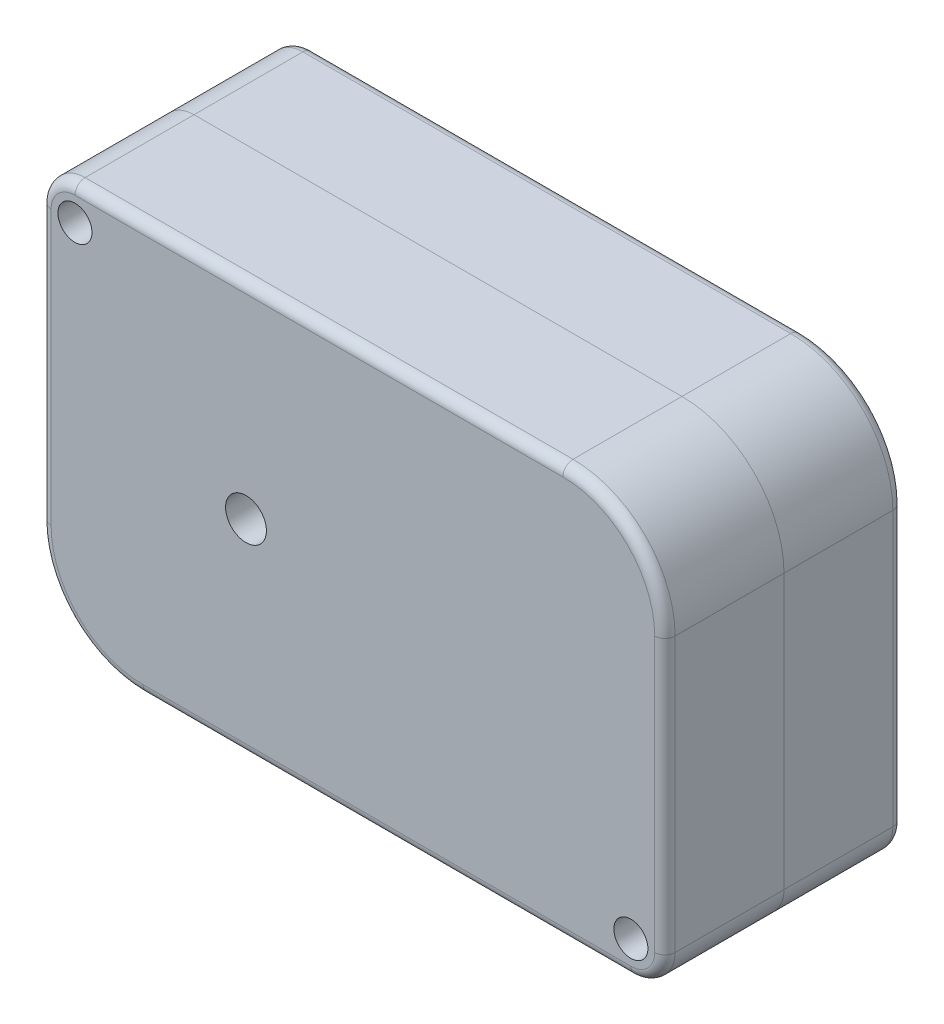
from build123d import *

# Parameters (mm, degrees)
SKETCH1_R           = 5
BOSS_EXTRUDE1_DEPTH = 25
BOSS_EXTRUDE5_DEPTH = 15
BOSS_EXTRUDE2_START = -10
SKETCH1_3_R         = 5
BOSS_EXTRUDE2_DEPTH = 10
FILLET1_R           = 3
SKETCH2_R           = 50
SKETCH2_R_2         = 6
BOSS_EXTRUDE6_DEPTH = 5
SKETCH2_3_R         = 6
CUT_EXTRUDE1_DEPTH  = 154.921216551
SKETCH3_R           = 2.5
CUT_EXTRUDE2_DEPTH  = 20


with BuildPart() as part:
    # Sketch1 → Boss-Extrude1 (new body)
    with BuildSketch(Plane.XY):
        with BuildLine():
            ThreePointArc((-113.122, 60.272), (-120.193067812, 57.343067812), (-123.122, 50.272))
            Line((-123.122, 50.272), (-123.122, -30.272))
            ThreePointArc((-123.122, -30.272), (-114.335203436, -51.485203436), (-93.122, -60.272))
            Line((-93.122, -60.272), (50.272, -60.272))
            ThreePointArc((50.272, -60.272), (57.343067812, -57.343067812), (60.272, -50.272))
            Line((60.272, -50.272), (60.272, 30.272))
            ThreePointArc((60.272, 30.272), (51.485203436, 51.485203436), (30.272, 60.272))
            Line((30.272, 60.272), (-113.122, 60.272))
        make_face()
        with BuildLine():
            ThreePointArc((28.192339385, 53.272), (42.618739916, 42.618739916), (53.272, 28.192339385))
            Line((53.272, 28.192339385), (53.272, -28.192339385))
            ThreePointArc((53.272, -28.192339385), (42.618739916, -42.618739916), (28.192339385, -53.272))
            Line((28.192339385, -53.272), (-91.042339385, -53.272))
            ThreePointArc((-91.042339385, -53.272), (-105.468739916, -42.618739916), (-116.122, -28.192339385))
            Line((-116.122, -28.192339385), (-116.122, 28.192339385))
            ThreePointArc((-116.122, 28.192339385), (-105.468739916, 42.618739916), (-91.042339385, 53.272))
            Line((-91.042339385, 53.272), (28.192339385, 53.272))
        make_face(mode=Mode.SUBTRACT)
        with Locations((-113.122, 50.272)):
            Circle(SKETCH1_R, mode=Mode.SUBTRACT)
        with Locations((50.272, -50.272)):
            Circle(SKETCH1_R, mode=Mode.SUBTRACT)
    extrude(amount=BOSS_EXTRUDE1_DEPTH)

    # Sketch1_5 → Boss-Extrude5 (add)
    with BuildSketch(Plane.XY):
        with BuildLine():
            Line((-62.85, 53.272), (-91.042339385, 53.272))
            ThreePointArc((-91.042339385, 53.272), (-105.468739916, 42.618739916), (-116.122, 28.192339385))
            Line((-116.122, 28.192339385), (-116.122, 0))
            ThreePointArc((-116.122, 0), (-100.518992447, 37.668992447), (-62.85, 53.272))
        make_face()
        with BuildLine():
            ThreePointArc((-62.85, 53.272), (-32.068882456, 43.479061475), (-12.604689069, 17.700698107))
            ThreePointArc((-12.604689069, 17.700698107), (21.73, 0), (-12.604689069, -17.700698107))
            ThreePointArc((-12.604689069, -17.700698107), (-32.068882456, -43.479061475), (-62.85, -53.272))
            Line((-62.85, -53.272), (28.192339385, -53.272))
            ThreePointArc((28.192339385, -53.272), (42.618739916, -42.618739916), (53.272, -28.192339385))
            Line((53.272, -28.192339385), (53.272, 28.192339385))
            ThreePointArc((53.272, 28.192339385), (42.618739916, 42.618739916), (28.192339385, 53.272))
            Line((28.192339385, 53.272), (-62.85, 53.272))
        make_face()
        with BuildLine():
            ThreePointArc((-62.85, -53.272), (-100.518992447, -37.668992447), (-116.122, 0))
            Line((-116.122, 0), (-116.122, -28.192339385))
            ThreePointArc((-116.122, -28.192339385), (-105.468739916, -42.618739916), (-91.042339385, -53.272))
            Line((-91.042339385, -53.272), (-62.85, -53.272))
        make_face()
    extrude(amount=BOSS_EXTRUDE5_DEPTH)

    # Sketch1_3 → Boss-Extrude2 (add)
    with BuildSketch(Plane.XY.offset(BOSS_EXTRUDE2_START)):
        with BuildLine():
            ThreePointArc((-113.122, 60.272), (-120.193067812, 57.343067812), (-123.122, 50.272))
            Line((-123.122, 50.272), (-123.122, -30.272))
            ThreePointArc((-123.122, -30.272), (-114.335203436, -51.485203436), (-93.122, -60.272))
            Line((-93.122, -60.272), (50.272, -60.272))
            ThreePointArc((50.272, -60.272), (57.343067812, -57.343067812), (60.272, -50.272))
            Line((60.272, -50.272), (60.272, 30.272))
            ThreePointArc((60.272, 30.272), (51.485203436, 51.485203436), (30.272, 60.272))
            Line((30.272, 60.272), (-113.122, 60.272))
        make_face()
        with Locations((-113.122, 50.272)):
            Circle(SKETCH1_3_R, mode=Mode.SUBTRACT)
        with Locations((50.272, -50.272)):
            Circle(SKETCH1_3_R, mode=Mode.SUBTRACT)
    extrude(amount=BOSS_EXTRUDE2_DEPTH)

    # Fillet1
    fillet1_edges = [part.edges().sort_by_distance(p)[0] for p in [
        (-21.425, -60.272, -10),
        (57.343067812, -57.343067812, -10),
        (60.272, -10, -10),
        (51.485203436, 51.485203436, -10),
        (-41.425, 60.272, -10),
        (-120.193067812, 57.343067812, -10),
        (-123.122, 10, -10),
        (-114.335203436, -51.485203436, -10),
    ]]
    fillet(fillet1_edges, radius=FILLET1_R)


with BuildPart() as body_2:
    # Mirror1: mirrored copy
    add(part.part.mirror(Plane.XY.offset(25)))


with BuildPart() as part_1:
    add(part.part)

    # Sketch2 → Boss-Extrude6 (add)
    with BuildSketch(Plane(origin=(0, 0, -10), x_dir=(-1, 0, 0), z_dir=(0, 0, -1))):
        with Locations((62.85, 0)):
            Circle(SKETCH2_R)
        with Locations((62.85, 0)):
            Circle(SKETCH2_R_2, mode=Mode.SUBTRACT)
    extrude(amount=BOSS_EXTRUDE6_DEPTH)


with BuildPart() as cut_extrude1_tool:
    # Sketch2_3 → Cut-Extrude1 (new, through all)
    with BuildSketch(Plane(origin=(0, 0, -10), x_dir=(-1, 0, 0), z_dir=(0, 0, -1))):
        with Locations((62.85, 0)):
            Circle(SKETCH2_3_R)
    extrude(amount=-CUT_EXTRUDE1_DEPTH)


with BuildPart() as part_2:
    add(part_1.part)

    # Cut-Extrude1: cut by cut_extrude1_tool
    add(cut_extrude1_tool.part, mode=Mode.SUBTRACT)

    # Sketch3 → Cut-Extrude2 (cut)
    with BuildSketch(Plane(origin=(0, 0, -15), x_dir=(-1, 0, 0), z_dir=(0, 0, -1))):
        with Locations((62.85, 35)):
            Circle(SKETCH3_R)
        with Locations((87.598737342, 24.748737342)):
            Circle(SKETCH3_R)
        with Locations((97.85, 0)):
            Circle(SKETCH3_R)
        with Locations((87.598737342, -24.748737342)):
            Circle(SKETCH3_R)
        with Locations((62.85, -35)):
            Circle(SKETCH3_R)
        with Locations((38.101262658, -24.748737342)):
            Circle(SKETCH3_R)
        with Locations((27.85, 0)):
            Circle(SKETCH3_R)
        with Locations((38.101262658, 24.748737342)):
            Circle(SKETCH3_R)
    extrude(amount=-CUT_EXTRUDE2_DEPTH, mode=Mode.SUBTRACT)


with BuildPart() as body_2_1:
    add(body_2.part)

    # Cut-Extrude1: cut by cut_extrude1_tool
    add(cut_extrude1_tool.part, mode=Mode.SUBTRACT)


solid = Compound([part_2.part, body_2_1.part])
